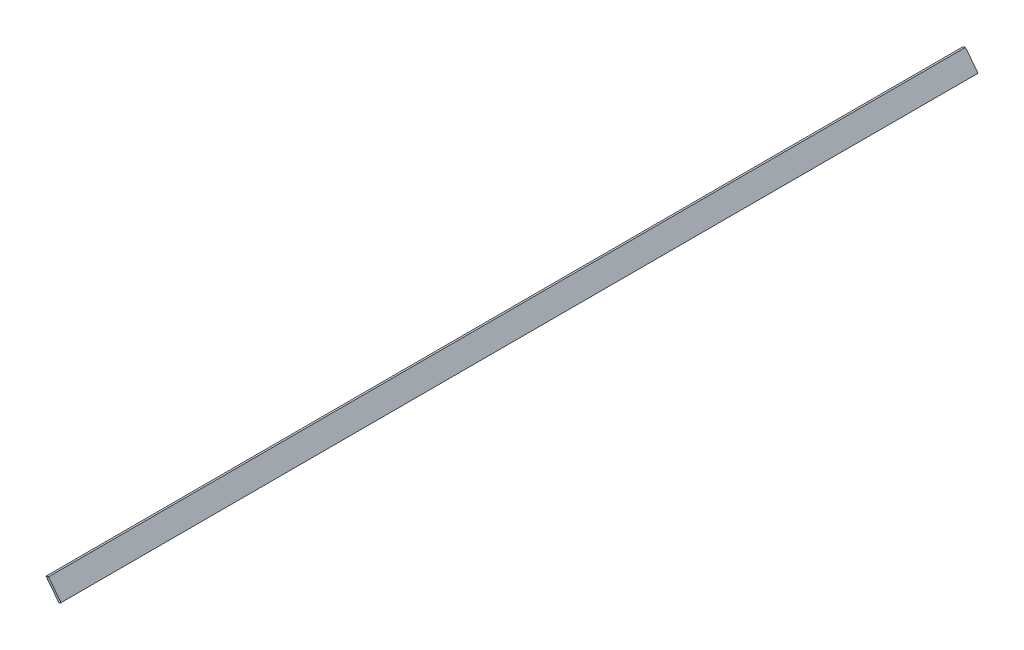
from build123d import *

# Parameters (mm, degrees)
BOSS_EXTRUDE1_DEPTH = 901.7


with BuildPart() as part:
    # Sketch1 → Boss-Extrude1 (new body)
    with BuildSketch(Plane.XY):
        Polygon((0, 0), (1.869125643, 1.444423128), (-10.423662837, 17.351649844), (-12.891088129, 16.681443908), align=None)
    extrude(amount=BOSS_EXTRUDE1_DEPTH)


solid = part.part
